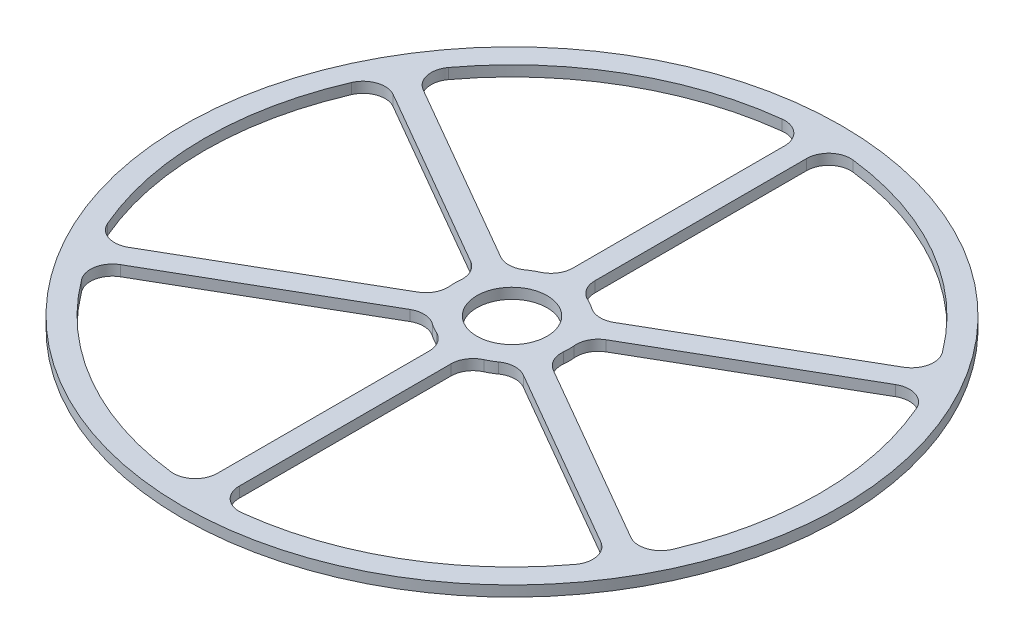
from build123d import *

# Parameters (mm, degrees)
SKETCH1_R           = 47.625
SKETCH1_R_2         = 5.08
BOSS_EXTRUDE1_DEPTH = 1.524


with BuildPart() as part:
    # Sketch1 → Boss-Extrude1 (new body)
    with BuildSketch(Plane(origin=(0, 0, 0), x_dir=(1, 0, 0), z_dir=(0, 1, 0))):
        Circle(SKETCH1_R)
        Circle(SKETCH1_R_2, mode=Mode.SUBTRACT)
        with BuildLine():
            Line((1.5875, 40.999319735), (1.5875, 10.390548289))
            ThreePointArc((1.5875, 10.390548289), (2.090339318, 8.675852313), (3.439583333, 7.504284876))
            ThreePointArc((3.439583333, 7.504284876), (4.1275, 7.149039708), (4.779109673, 6.730908983))
            ThreePointArc((4.779109673, 6.730908983), (6.468338843, 6.148213109), (8.204728778, 6.570089473))
            Line((8.204728778, 6.570089473), (34.712702429, 21.874475196))
            ThreePointArc((34.712702429, 21.874475196), (36.234379788, 23.980956457), (35.673294923, 26.518267842))
            ThreePointArc((35.673294923, 26.518267842), (22.225, 38.494829198), (5.128846154, 44.153113561))
            ThreePointArc((5.128846154, 44.153113561), (2.650927605, 43.370371616), (1.5875, 40.999319735))
        make_face(mode=Mode.SUBTRACT)
        with BuildLine():
            Line((36.300202429, 19.124844539), (9.792228778, 3.820458816))
            ThreePointArc((9.792228778, 3.820458816), (8.558678162, 2.527639204), (8.218693006, 0.773375893))
            ThreePointArc((8.218693006, 0.773375893), (8.255, 0), (8.218693006, -0.773375893))
            ThreePointArc((8.218693006, -0.773375893), (8.558678162, -2.527639204), (9.792228778, -3.820458816))
            Line((9.792228778, -3.820458816), (36.300202429, -19.124844539))
            ThreePointArc((36.300202429, -19.124844539), (38.885307393, -19.389415159), (40.802141077, -17.634845719))
            ThreePointArc((40.802141077, -17.634845719), (44.45, 0), (40.802141077, 17.634845719))
            ThreePointArc((40.802141077, 17.634845719), (38.885307393, 19.389415159), (36.300202429, 19.124844539))
        make_face(mode=Mode.SUBTRACT)
        with BuildLine():
            Line((34.712702429, -21.874475196), (8.204728778, -6.570089473))
            ThreePointArc((8.204728778, -6.570089473), (6.468338843, -6.148213109), (4.779109673, -6.730908983))
            ThreePointArc((4.779109673, -6.730908983), (4.1275, -7.149039708), (3.439583333, -7.504284876))
            ThreePointArc((3.439583333, -7.504284876), (2.090339318, -8.675852313), (1.5875, -10.390548289))
            Line((1.5875, -10.390548289), (1.5875, -40.999319735))
            ThreePointArc((1.5875, -40.999319735), (2.650927605, -43.370371616), (5.128846154, -44.153113561))
            ThreePointArc((5.128846154, -44.153113561), (22.225, -38.494829198), (35.673294923, -26.518267842))
            ThreePointArc((35.673294923, -26.518267842), (36.234379788, -23.980956457), (34.712702429, -21.874475196))
        make_face(mode=Mode.SUBTRACT)
        with BuildLine():
            Line((-1.5875, -40.999319735), (-1.5875, -10.390548289))
            ThreePointArc((-1.5875, -10.390548289), (-2.090339318, -8.675852313), (-3.439583333, -7.504284876))
            ThreePointArc((-3.439583333, -7.504284876), (-4.1275, -7.149039708), (-4.779109673, -6.730908983))
            ThreePointArc((-4.779109673, -6.730908983), (-6.468338843, -6.148213109), (-8.204728778, -6.570089473))
            Line((-8.204728778, -6.570089473), (-34.712702429, -21.874475196))
            ThreePointArc((-34.712702429, -21.874475196), (-36.234379788, -23.980956457), (-35.673294923, -26.518267842))
            ThreePointArc((-35.673294923, -26.518267842), (-22.225, -38.494829198), (-5.128846154, -44.153113561))
            ThreePointArc((-5.128846154, -44.153113561), (-2.650927605, -43.370371616), (-1.5875, -40.999319735))
        make_face(mode=Mode.SUBTRACT)
        with BuildLine():
            Line((-36.300202429, -19.124844539), (-9.792228778, -3.820458816))
            ThreePointArc((-9.792228778, -3.820458816), (-8.558678162, -2.527639204), (-8.218693006, -0.773375893))
            ThreePointArc((-8.218693006, -0.773375893), (-8.255, 0), (-8.218693006, 0.773375893))
            ThreePointArc((-8.218693006, 0.773375893), (-8.558678162, 2.527639204), (-9.792228778, 3.820458816))
            Line((-9.792228778, 3.820458816), (-36.300202429, 19.124844539))
            ThreePointArc((-36.300202429, 19.124844539), (-38.885307393, 19.389415159), (-40.802141077, 17.634845719))
            ThreePointArc((-40.802141077, 17.634845719), (-44.45, 0), (-40.802141077, -17.634845719))
            ThreePointArc((-40.802141077, -17.634845719), (-38.885307393, -19.389415159), (-36.300202429, -19.124844539))
        make_face(mode=Mode.SUBTRACT)
        with BuildLine():
            Line((-34.712702429, 21.874475196), (-8.204728778, 6.570089473))
            ThreePointArc((-8.204728778, 6.570089473), (-6.468338843, 6.148213109), (-4.779109673, 6.730908983))
            ThreePointArc((-4.779109673, 6.730908983), (-4.1275, 7.149039708), (-3.439583333, 7.504284876))
            ThreePointArc((-3.439583333, 7.504284876), (-2.090339318, 8.675852313), (-1.5875, 10.390548289))
            Line((-1.5875, 10.390548289), (-1.5875, 40.999319735))
            ThreePointArc((-1.5875, 40.999319735), (-2.650927605, 43.370371616), (-5.128846154, 44.153113561))
            ThreePointArc((-5.128846154, 44.153113561), (-22.225, 38.494829198), (-35.673294923, 26.518267842))
            ThreePointArc((-35.673294923, 26.518267842), (-36.234379788, 23.980956457), (-34.712702429, 21.874475196))
        make_face(mode=Mode.SUBTRACT)
    extrude(amount=BOSS_EXTRUDE1_DEPTH)


solid = part.part
